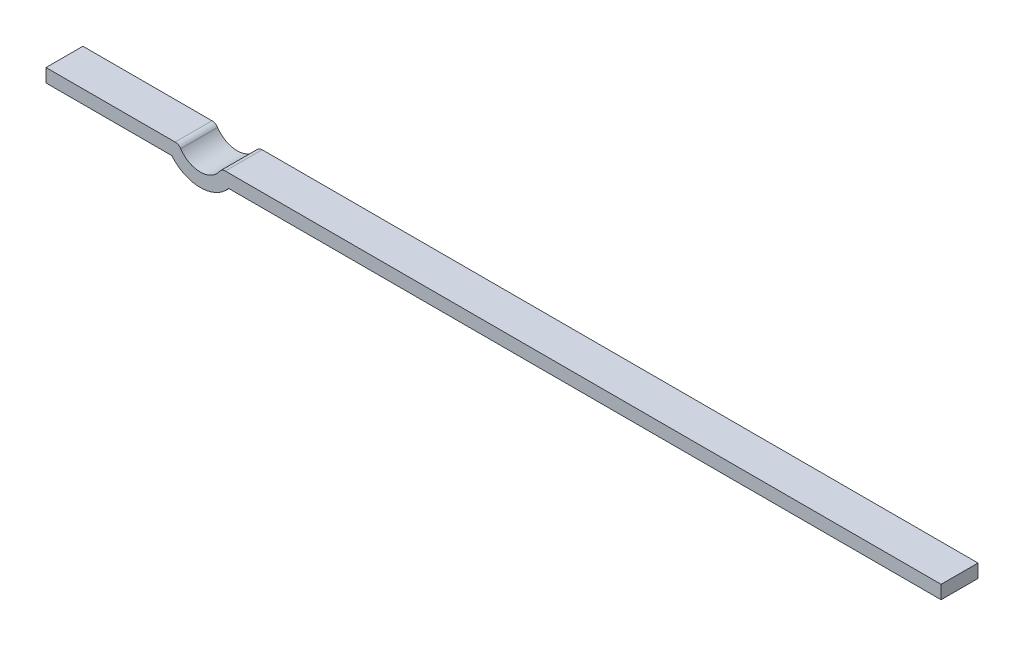
from build123d import *

# Parameters (mm, degrees)
RESSALTO_EXTRUS_O1_DEPTH = 0.55


with BuildPart() as part:
    # Esboço1 → Ressalto-extrusão1 (new body)
    with BuildSketch(Plane.XY):
        with BuildLine():
            Line((-4.000595656, 0.1), (6.675, 0.1))
            Line((6.675, 0.1), (6.675, -0.1))
            Line((6.675, -0.1), (-3.9505, -0.1))
            ThreePointArc((-3.9505, -0.1), (-4.37475, -0.299982947), (-4.799, -0.1))
            Line((-4.799, -0.1), (-6.675, -0.1))
            Line((-6.675, -0.1), (-6.675, 0.1))
            Line((-6.675, 0.1), (-4.748904344, 0.1))
            ThreePointArc((-4.748904344, 0.1), (-4.701765902, 0.088192785), (-4.665758934, 0.055559345))
            ThreePointArc((-4.665758934, 0.055559345), (-4.37475, -0.099982947), (-4.083741066, 0.055559345))
            ThreePointArc((-4.083741066, 0.055559345), (-4.047734098, 0.088192785), (-4.000595656, 0.1))
        make_face()
    extrude(amount=RESSALTO_EXTRUS_O1_DEPTH)


solid = part.part
